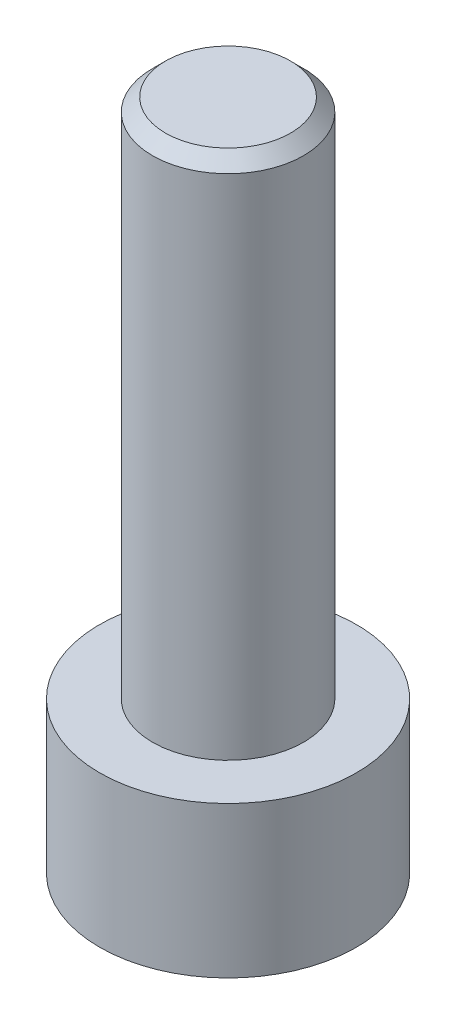
from build123d import *

# Parameters (mm, degrees)
SKETCH1_R           = 2.465
BOSS_EXTRUDE1_DEPTH = 2.9
SKETCH2_R           = 1.45
BOSS_EXTRUDE2_DEPTH = 10
CUT_EXTRUDE1_DEPTH  = 1.9
CHAMFER1_SIZE       = 0.25


with BuildPart() as part:
    # Sketch1 → Boss-Extrude1 (new body)
    with BuildSketch(Plane(origin=(0, 0, 0), x_dir=(1, 0, 0), z_dir=(0, 1, 0))):
        Circle(SKETCH1_R)
    extrude(amount=BOSS_EXTRUDE1_DEPTH)

    # Sketch2 → Boss-Extrude2 (add)
    with BuildSketch(Plane(origin=(0, 2.9, 0), x_dir=(1, 0, 0), z_dir=(0, 1, 0))):
        Circle(SKETCH2_R)
    extrude(amount=BOSS_EXTRUDE2_DEPTH)

    # Sketch3 → Cut-Extrude1 (cut)
    with BuildSketch(Plane.XZ):
        Polygon((0.733234842, -1.27), (1.466469684, 0), (0.733234842, 1.27), (-0.733234842, 1.27), (-1.466469684, 0), (-0.733234842, -1.27), align=None)
    extrude(amount=-CUT_EXTRUDE1_DEPTH, mode=Mode.SUBTRACT)

    # Chamfer1
    chamfer1_edges = [part.edges().sort_by_distance(p)[0] for p in [
        (-1.45, 12.9, 0),
    ]]
    chamfer(chamfer1_edges, length=CHAMFER1_SIZE)


solid = part.part
